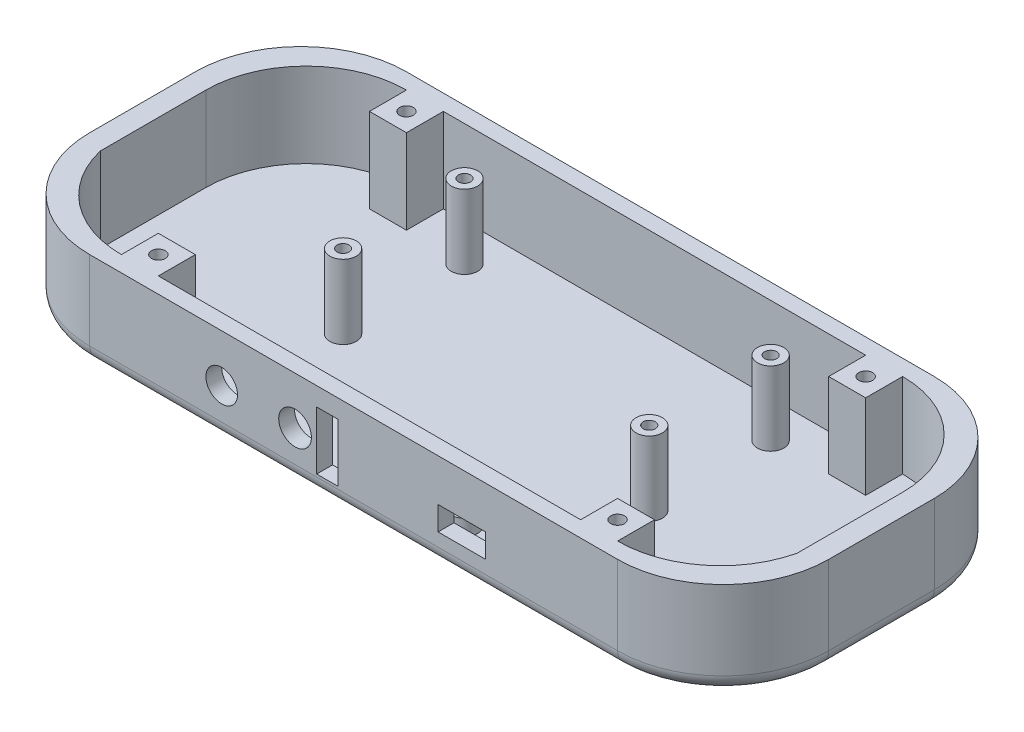
from build123d import *

# Parameters (mm, degrees)
BOSS_EXTRUDE1_DEPTH = 2
BOSS_EXTRUDE2_DEPTH = 16
SKETCH12_W          = 7
SKETCH12_H          = 7
BOSS_EXTRUDE5_DEPTH = 16
FILLET1_R           = 3
SKETCH13_R          = 1.3
CUT_EXTRUDE7_DEPTH  = 19
SKETCH14_R          = 2.5
SKETCH14_R_2        = 1.15
BOSS_EXTRUDE6_DEPTH = 14
SKETCH15_R          = 2.5
SKETCH15_R_2        = 1.3
BOSS_EXTRUDE7_DEPTH = 3
SKETCH16_W          = 9
SKETCH16_H          = 4.5
CUT_EXTRUDE8_DEPTH  = 4
SKETCH17_R          = 3.25
CUT_EXTRUDE9_DEPTH  = 13
SKETCH19_R          = 2.5
SKETCH19_R_2        = 1.15
BOSS_EXTRUDE8_DEPTH = 2.5
SKETCH20_R          = 3.1
SKETCH20_R_2        = 3
SKETCH20_W          = 4
SKETCH20_H          = 11
CUT_EXTRUDE10_DEPTH = 5
SKETCH21_R          = 1.15
CUT_EXTRUDE11_DEPTH = 3.5
SKETCH22_R          = 1.15
CUT_EXTRUDE12_DEPTH = 3.5


with BuildPart() as part:
    # Sketch1 → Boss-Extrude1 (new body)
    with BuildSketch(Plane(origin=(0, 0, 0), x_dir=(1, 0, 0), z_dir=(0, 1, 0))):
        with BuildLine():
            Line((70, 10), (70, -10))
            ThreePointArc((70, -10), (64.142135624, -24.142135624), (50, -30))
            Line((50, -30), (-50, -30))
            ThreePointArc((-50, -30), (-64.142135624, -24.142135624), (-70, -10))
            Line((-70, -10), (-70, 10))
            ThreePointArc((-70, 10), (-64.142135624, 24.142135624), (-50, 30))
            Line((-50, 30), (50, 30))
            ThreePointArc((50, 30), (64.142135624, 24.142135624), (70, 10))
        make_face()
    extrude(amount=BOSS_EXTRUDE1_DEPTH)

    # Sketch2 → Boss-Extrude2 (add)
    with BuildSketch(Plane(origin=(0, 2, 0), x_dir=(1, 0, 0), z_dir=(0, 1, 0))):
        with BuildLine():
            Line((-50, 30), (50, 30))
            ThreePointArc((50, 30), (64.142135624, 24.142135624), (70, 10))
            Line((70, 10), (70, -10))
            ThreePointArc((70, -10), (64.142135624, -24.142135624), (50, -30))
            Line((50, -30), (-50, -30))
            ThreePointArc((-50, -30), (-64.142135624, -24.142135624), (-70, -10))
            Line((-70, -10), (-70, 10))
            ThreePointArc((-70, 10), (-64.142135624, 24.142135624), (-50, 30))
        make_face()
        with BuildLine():
            Line((-47, 27), (47, 27))
            ThreePointArc((47, 27), (60.435028843, 21.435028843), (66, 8))
            Line((66, 8), (66, -12))
            ThreePointArc((66, -12), (59.103718437, -22.798043353), (47, -27))
            Line((47, -27), (-47, -27))
            ThreePointArc((-47, -27), (-59.103718437, -22.798043353), (-66, -12))
            Line((-66, -12), (-66, 8))
            ThreePointArc((-66, 8), (-60.435028843, 21.435028843), (-47, 27))
        make_face(mode=Mode.SUBTRACT)
    extrude(amount=BOSS_EXTRUDE2_DEPTH)

    # Sketch12 → Boss-Extrude5 (add)
    with BuildSketch(Plane(origin=(0, 2, 0), x_dir=(1, 0, 0), z_dir=(0, 1, 0))):
        with Locations((-43.5, 23.5)):
            Rectangle(SKETCH12_W, SKETCH12_H)
        with Locations((-43.5, -23.5)):
            Rectangle(SKETCH12_W, SKETCH12_H)
        with Locations((43.5, -23.5)):
            Rectangle(SKETCH12_W, SKETCH12_H)
        with Locations((43.5, 23.5)):
            Rectangle(SKETCH12_W, SKETCH12_H)
    extrude(amount=BOSS_EXTRUDE5_DEPTH)

    # Fillet1
    fillet1_edges = [part.edges().sort_by_distance(p)[0] for p in [
        (70, 0, 0),
        (64.142135624, 0, 24.142135624),
        (0, 0, 30),
        (-64.142135624, 0, 24.142135624),
        (-70, 0, 0),
        (-64.142135624, 0, -24.142135624),
        (0, 0, -30),
        (64.142135624, 0, -24.142135624),
    ]]
    fillet(fillet1_edges, radius=FILLET1_R)

    # Sketch13 → Cut-Extrude7 (cut, through all)
    with BuildSketch(Plane(origin=(0, 18, 0), x_dir=(1, 0, 0), z_dir=(0, 1, 0))):
        with Locations((-43.5, 23.5)):
            Circle(SKETCH13_R)
        with Locations((-43.5, -23.5)):
            Circle(SKETCH13_R)
        with Locations((43.5, -23.5)):
            Circle(SKETCH13_R)
        with Locations((43.5, 23.5)):
            Circle(SKETCH13_R)
    extrude(amount=-CUT_EXTRUDE7_DEPTH, mode=Mode.SUBTRACT)

    # Sketch14 → Boss-Extrude6 (add)
    with BuildSketch(Plane(origin=(0, 2, 0), x_dir=(1, 0, 0), z_dir=(0, 1, 0))):
        with Locations((29, -3)):
            Circle(SKETCH14_R)
        with Locations((29, -3)):
            Circle(SKETCH14_R_2, mode=Mode.SUBTRACT)
        with Locations((29, 20)):
            Circle(SKETCH14_R)
        with Locations((29, 20)):
            Circle(SKETCH14_R_2, mode=Mode.SUBTRACT)
        with Locations((-29, 20)):
            Circle(SKETCH14_R)
        with Locations((-29, 20)):
            Circle(SKETCH14_R_2, mode=Mode.SUBTRACT)
        with Locations((-29, -3)):
            Circle(SKETCH14_R)
        with Locations((-29, -3)):
            Circle(SKETCH14_R_2, mode=Mode.SUBTRACT)
    extrude(amount=BOSS_EXTRUDE6_DEPTH)

    # Sketch15 → Boss-Extrude7 (add)
    with BuildSketch(Plane(origin=(0, 2, 0), x_dir=(1, 0, 0), z_dir=(0, 1, 0))):
        with Locations((29, -23)):
            Circle(SKETCH15_R)
        with Locations((29, -23)):
            Circle(SKETCH15_R_2, mode=Mode.SUBTRACT)
        with Locations((14, -23)):
            Circle(SKETCH15_R)
        with Locations((14, -23)):
            Circle(SKETCH15_R_2, mode=Mode.SUBTRACT)
    extrude(amount=BOSS_EXTRUDE7_DEPTH)

    # Sketch16 → Cut-Extrude8 (cut, through all)
    with BuildSketch(Plane(origin=(0, 0, 27), x_dir=(-1, 0, 0), z_dir=(0, 0, -1))):
        with Locations((-20.5, 7.75)):
            Rectangle(SKETCH16_W, SKETCH16_H)
    extrude(amount=-CUT_EXTRUDE8_DEPTH, mode=Mode.SUBTRACT)

    # Sketch17 → Cut-Extrude9 (cut)
    with BuildSketch(Plane.XZ):
        with Locations((-43.5, 23.5)):
            Circle(SKETCH17_R)
        with Locations((43.5, 23.5)):
            Circle(SKETCH17_R)
        with Locations((43.5, -23.5)):
            Circle(SKETCH17_R)
        with Locations((-43.5, -23.5)):
            Circle(SKETCH17_R)
    extrude(amount=-CUT_EXTRUDE9_DEPTH, mode=Mode.SUBTRACT)

    # Sketch19 → Boss-Extrude8 (add)
    with BuildSketch(Plane(origin=(0, 0, 27), x_dir=(-1, 0, 0), z_dir=(0, 0, -1))):
        with Locations((-1, 9)):
            Circle(SKETCH19_R)
        with Locations((-1, 9)):
            Circle(SKETCH19_R_2, mode=Mode.SUBTRACT)
        with Locations((34, 9)):
            Circle(SKETCH19_R)
        with Locations((34, 9)):
            Circle(SKETCH19_R_2, mode=Mode.SUBTRACT)
    extrude(amount=BOSS_EXTRUDE8_DEPTH)

    # Sketch20 → Cut-Extrude10 (cut)
    with BuildSketch(Plane(origin=(0, 0, 27), x_dir=(-1, 0, 0), z_dir=(0, 0, -1))):
        with Locations((11.1, 9)):
            Circle(SKETCH20_R)
        with Locations((25, 9)):
            Circle(SKETCH20_R_2)
        with Locations((5, 9)):
            Rectangle(SKETCH20_W, SKETCH20_H)
    extrude(amount=-CUT_EXTRUDE10_DEPTH, mode=Mode.SUBTRACT)

    # Sketch21 → Cut-Extrude11 (cut)
    with BuildSketch(Plane(origin=(0, 0, 24.5), x_dir=(-1, 0, 0), z_dir=(0, 0, -1))):
        with Locations((-1, 9)):
            Circle(SKETCH21_R)
    extrude(amount=-CUT_EXTRUDE11_DEPTH, mode=Mode.SUBTRACT)

    # Sketch22 → Cut-Extrude12 (cut)
    with BuildSketch(Plane(origin=(0, 0, 24.5), x_dir=(-1, 0, 0), z_dir=(0, 0, -1))):
        with Locations((34, 9)):
            Circle(SKETCH22_R)
    extrude(amount=-CUT_EXTRUDE12_DEPTH, mode=Mode.SUBTRACT)


solid = part.part
